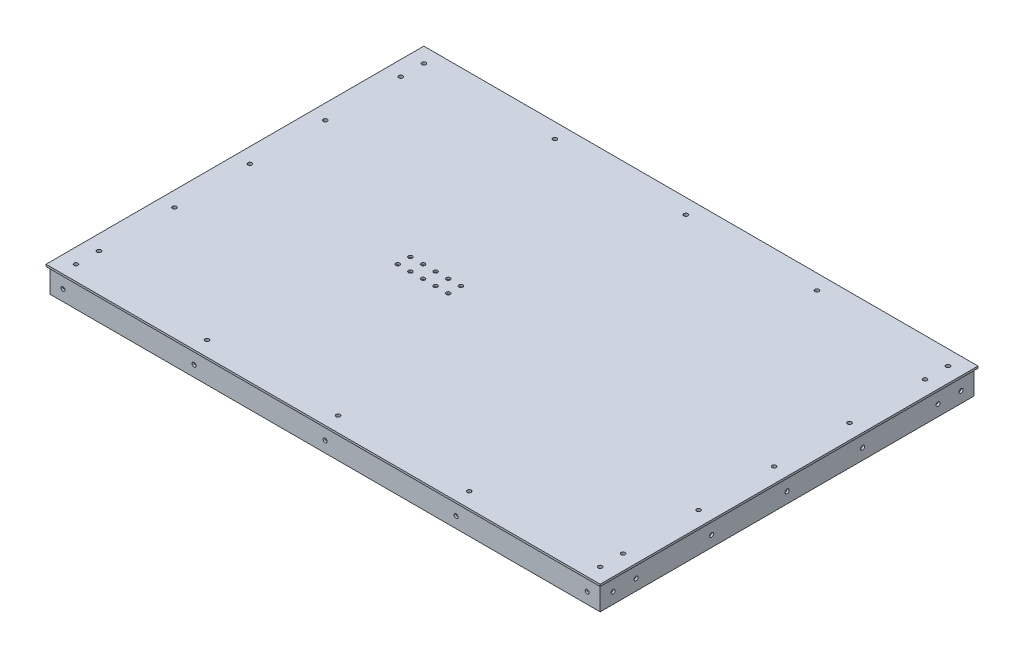
from build123d import *

# Parameters (mm, degrees)
ESQUISSE2_W              = 436.825
ESQUISSE2_H              = 296.825
ESQUISSE2_W_2            = 398.725
ESQUISSE2_H_2            = 258.725
BOSS_EXTRU_2_DEPTH       = 1.5875
ESQUISSE3_W              = 436.825
ESQUISSE3_H              = 296.825
ESQUISSE3_W_2            = 433.65
ESQUISSE3_H_2            = 293.65
BOSS_EXTRU_3_DEPTH       = 17.4625
ENL_V_MAT_EXTRU_1_REACH  = 21.05
ESQUISSE6_R              = 1.5875
ENL_V_MAT_EXTRU_2_REACH  = 3.588
ESQUISSE7_R              = 1.5875
ENL_V_MAT_EXTRU_3_REACH  = 3.588
ESQUISSE8_R              = 1.5875
ENL_V_MAT_EXTRU_4_REACH  = 3.588
ESQUISSE9_R              = 1.5875
ENL_V_MAT_EXTRU_6_REACH  = 298.825
ESQUISSE10_R             = 2
ESQUISSE1_W              = 440
ESQUISSE1_H              = 300
ESQUISSE1_R              = 1.5875
BOSS_EXTRU_7_DEPTH       = 1.5875
ENL_V_MAT_EXTRU_10_REACH = 5.175
ESQUISSE16_R             = 1.5875
ENL_V_MAT_EXTRU_11_REACH = 22.637
ESQUISSE17_R             = 1.5875


with BuildPart() as part:
    # Esquisse2 → Boss.-Extru.2 (new body)
    with BuildSketch(Plane(origin=(0, 0, 0), x_dir=(1, 0, 0), z_dir=(0, 1, 0))):
        with Locations((-37.473544974, -105.522486772)):
            Rectangle(ESQUISSE2_W, ESQUISSE2_H)
        with Locations((-37.473544974, -105.522486772)):
            Rectangle(ESQUISSE2_W_2, ESQUISSE2_H_2, mode=Mode.SUBTRACT)
    extrude(amount=BOSS_EXTRU_2_DEPTH)

    # Esquisse3 → Boss.-Extru.3 (add)
    with BuildSketch(Plane(origin=(0, 0, 0), x_dir=(1, 0, 0), z_dir=(0, 1, 0))):
        with Locations((-37.473544974, -105.522486772)):
            Rectangle(ESQUISSE3_W, ESQUISSE3_H)
        with Locations((-37.473544974, -105.522486772)):
            Rectangle(ESQUISSE3_W_2, ESQUISSE3_H_2, mode=Mode.SUBTRACT)
    extrude(amount=-BOSS_EXTRU_3_DEPTH)

    # Esquisse6 → Enlèv. mat.-Extru.1 (cut, up to next)
    with BuildSketch(Plane(origin=(0, 1.5875, 0), x_dir=(1, 0, 0), z_dir=(0, 1, 0)), mode=Mode.PRIVATE) as enl_v_mat_extru_1_sk1:
        with Locations((-245.567294974, -243.616236772)):
            Circle(ESQUISSE6_R)
    enl_v_mat_extru_1_tool1 = extrude(enl_v_mat_extru_1_sk1.sketch, amount=-ENL_V_MAT_EXTRU_1_REACH, mode=Mode.PRIVATE) & part.part
    add(enl_v_mat_extru_1_tool1.solids().sort_by_distance((-245.567295, 1.5875, 243.616237))[0], mode=Mode.SUBTRACT)
    # Esquisse6 → Enlèv. mat.-Extru.1 (cut, up to next)
    with BuildSketch(Plane(origin=(0, 1.5875, 0), x_dir=(1, 0, 0), z_dir=(0, 1, 0)), mode=Mode.PRIVATE) as enl_v_mat_extru_1_sk2:
        with Locations((170.620205026, -243.616236772)):
            Circle(ESQUISSE6_R)
    enl_v_mat_extru_1_tool2 = extrude(enl_v_mat_extru_1_sk2.sketch, amount=-ENL_V_MAT_EXTRU_1_REACH, mode=Mode.PRIVATE) & part.part
    add(enl_v_mat_extru_1_tool2.solids().sort_by_distance((170.620205, 1.5875, 243.616237))[0], mode=Mode.SUBTRACT)
    # Esquisse6 → Enlèv. mat.-Extru.1 (cut, up to next)
    with BuildSketch(Plane(origin=(0, 1.5875, 0), x_dir=(1, 0, 0), z_dir=(0, 1, 0)), mode=Mode.PRIVATE) as enl_v_mat_extru_1_sk3:
        with Locations((-245.567294974, 32.571263228)):
            Circle(ESQUISSE6_R)
    enl_v_mat_extru_1_tool3 = extrude(enl_v_mat_extru_1_sk3.sketch, amount=-ENL_V_MAT_EXTRU_1_REACH, mode=Mode.PRIVATE) & part.part
    add(enl_v_mat_extru_1_tool3.solids().sort_by_distance((-245.567295, 1.5875, -32.571263))[0], mode=Mode.SUBTRACT)
    # Esquisse6 → Enlèv. mat.-Extru.1 (cut, up to next)
    with BuildSketch(Plane(origin=(0, 1.5875, 0), x_dir=(1, 0, 0), z_dir=(0, 1, 0)), mode=Mode.PRIVATE) as enl_v_mat_extru_1_sk4:
        with Locations((170.620205026, 32.571263228)):
            Circle(ESQUISSE6_R)
    enl_v_mat_extru_1_tool4 = extrude(enl_v_mat_extru_1_sk4.sketch, amount=-ENL_V_MAT_EXTRU_1_REACH, mode=Mode.PRIVATE) & part.part
    add(enl_v_mat_extru_1_tool4.solids().sort_by_distance((170.620205, 1.5875, -32.571263))[0], mode=Mode.SUBTRACT)
    # Esquisse6 → Enlèv. mat.-Extru.1 (cut, up to next)
    with BuildSketch(Plane(origin=(0, 1.5875, 0), x_dir=(1, 0, 0), z_dir=(0, 1, 0)), mode=Mode.PRIVATE) as enl_v_mat_extru_1_sk5:
        with Locations((-141.520419974, -243.616236772)):
            Circle(ESQUISSE6_R)
    enl_v_mat_extru_1_tool5 = extrude(enl_v_mat_extru_1_sk5.sketch, amount=-ENL_V_MAT_EXTRU_1_REACH, mode=Mode.PRIVATE) & part.part
    add(enl_v_mat_extru_1_tool5.solids().sort_by_distance((-141.52042, 1.5875, 243.616237))[0], mode=Mode.SUBTRACT)
    # Esquisse6 → Enlèv. mat.-Extru.1 (cut, up to next)
    with BuildSketch(Plane(origin=(0, 1.5875, 0), x_dir=(1, 0, 0), z_dir=(0, 1, 0)), mode=Mode.PRIVATE) as enl_v_mat_extru_1_sk6:
        with Locations((66.573330026, -243.616236772)):
            Circle(ESQUISSE6_R)
    enl_v_mat_extru_1_tool6 = extrude(enl_v_mat_extru_1_sk6.sketch, amount=-ENL_V_MAT_EXTRU_1_REACH, mode=Mode.PRIVATE) & part.part
    add(enl_v_mat_extru_1_tool6.solids().sort_by_distance((66.57333, 1.5875, 243.616237))[0], mode=Mode.SUBTRACT)
    # Esquisse6 → Enlèv. mat.-Extru.1 (cut, up to next)
    with BuildSketch(Plane(origin=(0, 1.5875, 0), x_dir=(1, 0, 0), z_dir=(0, 1, 0)), mode=Mode.PRIVATE) as enl_v_mat_extru_1_sk7:
        with Locations((66.573330026, 32.571263228)):
            Circle(ESQUISSE6_R)
    enl_v_mat_extru_1_tool7 = extrude(enl_v_mat_extru_1_sk7.sketch, amount=-ENL_V_MAT_EXTRU_1_REACH, mode=Mode.PRIVATE) & part.part
    add(enl_v_mat_extru_1_tool7.solids().sort_by_distance((66.57333, 1.5875, -32.571263))[0], mode=Mode.SUBTRACT)
    # Esquisse6 → Enlèv. mat.-Extru.1 (cut, up to next)
    with BuildSketch(Plane(origin=(0, 1.5875, 0), x_dir=(1, 0, 0), z_dir=(0, 1, 0)), mode=Mode.PRIVATE) as enl_v_mat_extru_1_sk8:
        with Locations((-141.520419974, 32.571263228)):
            Circle(ESQUISSE6_R)
    enl_v_mat_extru_1_tool8 = extrude(enl_v_mat_extru_1_sk8.sketch, amount=-ENL_V_MAT_EXTRU_1_REACH, mode=Mode.PRIVATE) & part.part
    add(enl_v_mat_extru_1_tool8.solids().sort_by_distance((-141.52042, 1.5875, -32.571263))[0], mode=Mode.SUBTRACT)
    # Esquisse6 → Enlèv. mat.-Extru.1 (cut, up to next)
    with BuildSketch(Plane(origin=(0, 1.5875, 0), x_dir=(1, 0, 0), z_dir=(0, 1, 0)), mode=Mode.PRIVATE) as enl_v_mat_extru_1_sk9:
        with Locations((170.620205026, -45.603736772)):
            Circle(ESQUISSE6_R)
    enl_v_mat_extru_1_tool9 = extrude(enl_v_mat_extru_1_sk9.sketch, amount=-ENL_V_MAT_EXTRU_1_REACH, mode=Mode.PRIVATE) & part.part
    add(enl_v_mat_extru_1_tool9.solids().sort_by_distance((170.620205, 1.5875, 45.603737))[0], mode=Mode.SUBTRACT)
    # Esquisse6 → Enlèv. mat.-Extru.1 (cut, up to next)
    with BuildSketch(Plane(origin=(0, 1.5875, 0), x_dir=(1, 0, 0), z_dir=(0, 1, 0)), mode=Mode.PRIVATE) as enl_v_mat_extru_1_sk10:
        with Locations((-37.473544974, -243.616236772)):
            Circle(ESQUISSE6_R)
    enl_v_mat_extru_1_tool10 = extrude(enl_v_mat_extru_1_sk10.sketch, amount=-ENL_V_MAT_EXTRU_1_REACH, mode=Mode.PRIVATE) & part.part
    add(enl_v_mat_extru_1_tool10.solids().sort_by_distance((-37.473545, 1.5875, 243.616237))[0], mode=Mode.SUBTRACT)
    # Esquisse6 → Enlèv. mat.-Extru.1 (cut, up to next)
    with BuildSketch(Plane(origin=(0, 1.5875, 0), x_dir=(1, 0, 0), z_dir=(0, 1, 0)), mode=Mode.PRIVATE) as enl_v_mat_extru_1_sk11:
        with Locations((-37.473544974, 32.571263228)):
            Circle(ESQUISSE6_R)
    enl_v_mat_extru_1_tool11 = extrude(enl_v_mat_extru_1_sk11.sketch, amount=-ENL_V_MAT_EXTRU_1_REACH, mode=Mode.PRIVATE) & part.part
    add(enl_v_mat_extru_1_tool11.solids().sort_by_distance((-37.473545, 1.5875, -32.571263))[0], mode=Mode.SUBTRACT)
    # Esquisse6 → Enlèv. mat.-Extru.1 (cut, up to next)
    with BuildSketch(Plane(origin=(0, 1.5875, 0), x_dir=(1, 0, 0), z_dir=(0, 1, 0)), mode=Mode.PRIVATE) as enl_v_mat_extru_1_sk12:
        with Locations((170.620205026, -165.441236772)):
            Circle(ESQUISSE6_R)
    enl_v_mat_extru_1_tool12 = extrude(enl_v_mat_extru_1_sk12.sketch, amount=-ENL_V_MAT_EXTRU_1_REACH, mode=Mode.PRIVATE) & part.part
    add(enl_v_mat_extru_1_tool12.solids().sort_by_distance((170.620205, 1.5875, 165.441237))[0], mode=Mode.SUBTRACT)
    # Esquisse6 → Enlèv. mat.-Extru.1 (cut, up to next)
    with BuildSketch(Plane(origin=(0, 1.5875, 0), x_dir=(1, 0, 0), z_dir=(0, 1, 0)), mode=Mode.PRIVATE) as enl_v_mat_extru_1_sk13:
        with Locations((-245.567294974, -165.441236772)):
            Circle(ESQUISSE6_R)
    enl_v_mat_extru_1_tool13 = extrude(enl_v_mat_extru_1_sk13.sketch, amount=-ENL_V_MAT_EXTRU_1_REACH, mode=Mode.PRIVATE) & part.part
    add(enl_v_mat_extru_1_tool13.solids().sort_by_distance((-245.567295, 1.5875, 165.441237))[0], mode=Mode.SUBTRACT)
    # Esquisse6 → Enlèv. mat.-Extru.1 (cut, up to next)
    with BuildSketch(Plane(origin=(0, 1.5875, 0), x_dir=(1, 0, 0), z_dir=(0, 1, 0)), mode=Mode.PRIVATE) as enl_v_mat_extru_1_sk14:
        with Locations((-245.567294974, -45.603736772)):
            Circle(ESQUISSE6_R)
    enl_v_mat_extru_1_tool14 = extrude(enl_v_mat_extru_1_sk14.sketch, amount=-ENL_V_MAT_EXTRU_1_REACH, mode=Mode.PRIVATE) & part.part
    add(enl_v_mat_extru_1_tool14.solids().sort_by_distance((-245.567295, 1.5875, 45.603737))[0], mode=Mode.SUBTRACT)
    # Esquisse6 → Enlèv. mat.-Extru.1 (cut, up to next)
    with BuildSketch(Plane(origin=(0, 1.5875, 0), x_dir=(1, 0, 0), z_dir=(0, 1, 0)), mode=Mode.PRIVATE) as enl_v_mat_extru_1_sk15:
        with Locations((-245.567294974, -225.359986772)):
            Circle(ESQUISSE6_R)
    enl_v_mat_extru_1_tool15 = extrude(enl_v_mat_extru_1_sk15.sketch, amount=-ENL_V_MAT_EXTRU_1_REACH, mode=Mode.PRIVATE) & part.part
    add(enl_v_mat_extru_1_tool15.solids().sort_by_distance((-245.567295, 1.5875, 225.359987))[0], mode=Mode.SUBTRACT)
    # Esquisse6 → Enlèv. mat.-Extru.1 (cut, up to next)
    with BuildSketch(Plane(origin=(0, 1.5875, 0), x_dir=(1, 0, 0), z_dir=(0, 1, 0)), mode=Mode.PRIVATE) as enl_v_mat_extru_1_sk16:
        with Locations((-245.567294974, 14.315013228)):
            Circle(ESQUISSE6_R)
    enl_v_mat_extru_1_tool16 = extrude(enl_v_mat_extru_1_sk16.sketch, amount=-ENL_V_MAT_EXTRU_1_REACH, mode=Mode.PRIVATE) & part.part
    add(enl_v_mat_extru_1_tool16.solids().sort_by_distance((-245.567295, 1.5875, -14.315013))[0], mode=Mode.SUBTRACT)
    # Esquisse6 → Enlèv. mat.-Extru.1 (cut, up to next)
    with BuildSketch(Plane(origin=(0, 1.5875, 0), x_dir=(1, 0, 0), z_dir=(0, 1, 0)), mode=Mode.PRIVATE) as enl_v_mat_extru_1_sk17:
        with Locations((170.620205026, 14.315013228)):
            Circle(ESQUISSE6_R)
    enl_v_mat_extru_1_tool17 = extrude(enl_v_mat_extru_1_sk17.sketch, amount=-ENL_V_MAT_EXTRU_1_REACH, mode=Mode.PRIVATE) & part.part
    add(enl_v_mat_extru_1_tool17.solids().sort_by_distance((170.620205, 1.5875, -14.315013))[0], mode=Mode.SUBTRACT)
    # Esquisse6 → Enlèv. mat.-Extru.1 (cut, up to next)
    with BuildSketch(Plane(origin=(0, 1.5875, 0), x_dir=(1, 0, 0), z_dir=(0, 1, 0)), mode=Mode.PRIVATE) as enl_v_mat_extru_1_sk18:
        with Locations((170.620205026, -225.359986772)):
            Circle(ESQUISSE6_R)
    enl_v_mat_extru_1_tool18 = extrude(enl_v_mat_extru_1_sk18.sketch, amount=-ENL_V_MAT_EXTRU_1_REACH, mode=Mode.PRIVATE) & part.part
    add(enl_v_mat_extru_1_tool18.solids().sort_by_distance((170.620205, 1.5875, 225.359987))[0], mode=Mode.SUBTRACT)
    # Esquisse6 → Enlèv. mat.-Extru.1 (cut, up to next)
    with BuildSketch(Plane(origin=(0, 1.5875, 0), x_dir=(1, 0, 0), z_dir=(0, 1, 0)), mode=Mode.PRIVATE) as enl_v_mat_extru_1_sk19:
        with Locations((-245.567294974, -105.522486772)):
            Circle(ESQUISSE6_R)
    enl_v_mat_extru_1_tool19 = extrude(enl_v_mat_extru_1_sk19.sketch, amount=-ENL_V_MAT_EXTRU_1_REACH, mode=Mode.PRIVATE) & part.part
    add(enl_v_mat_extru_1_tool19.solids().sort_by_distance((-245.567295, 1.5875, 105.522487))[0], mode=Mode.SUBTRACT)
    # Esquisse6 → Enlèv. mat.-Extru.1 (cut, up to next)
    with BuildSketch(Plane(origin=(0, 1.5875, 0), x_dir=(1, 0, 0), z_dir=(0, 1, 0)), mode=Mode.PRIVATE) as enl_v_mat_extru_1_sk20:
        with Locations((170.620205026, -105.522486772)):
            Circle(ESQUISSE6_R)
    enl_v_mat_extru_1_tool20 = extrude(enl_v_mat_extru_1_sk20.sketch, amount=-ENL_V_MAT_EXTRU_1_REACH, mode=Mode.PRIVATE) & part.part
    add(enl_v_mat_extru_1_tool20.solids().sort_by_distance((170.620205, 1.5875, 105.522487))[0], mode=Mode.SUBTRACT)

    # Esquisse7 → Enlèv. mat.-Extru.2 (cut, up to next)
    with BuildSketch(Plane.ZY.offset(-179.351455026), mode=Mode.PRIVATE) as enl_v_mat_extru_2_sk1:
        with Locations((-32.571263228, -8.73125)):
            Circle(ESQUISSE7_R)
    enl_v_mat_extru_2_tool1 = extrude(enl_v_mat_extru_2_sk1.sketch, amount=-ENL_V_MAT_EXTRU_2_REACH, mode=Mode.PRIVATE) & part.part
    add(enl_v_mat_extru_2_tool1.solids().sort_by_distance((179.351455, -8.73125, -32.571263))[0], mode=Mode.SUBTRACT)
    # Esquisse7 → Enlèv. mat.-Extru.2 (cut, up to next)
    with BuildSketch(Plane.ZY.offset(-179.351455026), mode=Mode.PRIVATE) as enl_v_mat_extru_2_sk2:
        with Locations((-14.315013228, -8.73125)):
            Circle(ESQUISSE7_R)
    enl_v_mat_extru_2_tool2 = extrude(enl_v_mat_extru_2_sk2.sketch, amount=-ENL_V_MAT_EXTRU_2_REACH, mode=Mode.PRIVATE) & part.part
    add(enl_v_mat_extru_2_tool2.solids().sort_by_distance((179.351455, -8.73125, -14.315013))[0], mode=Mode.SUBTRACT)
    # Esquisse7 → Enlèv. mat.-Extru.2 (cut, up to next)
    with BuildSketch(Plane.ZY.offset(-179.351455026), mode=Mode.PRIVATE) as enl_v_mat_extru_2_sk3:
        with Locations((45.603736772, -8.73125)):
            Circle(ESQUISSE7_R)
    enl_v_mat_extru_2_tool3 = extrude(enl_v_mat_extru_2_sk3.sketch, amount=-ENL_V_MAT_EXTRU_2_REACH, mode=Mode.PRIVATE) & part.part
    add(enl_v_mat_extru_2_tool3.solids().sort_by_distance((179.351455, -8.73125, 45.603737))[0], mode=Mode.SUBTRACT)
    # Esquisse7 → Enlèv. mat.-Extru.2 (cut, up to next)
    with BuildSketch(Plane.ZY.offset(-179.351455026), mode=Mode.PRIVATE) as enl_v_mat_extru_2_sk4:
        with Locations((105.522486772, -8.73125)):
            Circle(ESQUISSE7_R)
    enl_v_mat_extru_2_tool4 = extrude(enl_v_mat_extru_2_sk4.sketch, amount=-ENL_V_MAT_EXTRU_2_REACH, mode=Mode.PRIVATE) & part.part
    add(enl_v_mat_extru_2_tool4.solids().sort_by_distance((179.351455, -8.73125, 105.522487))[0], mode=Mode.SUBTRACT)
    # Esquisse7 → Enlèv. mat.-Extru.2 (cut, up to next)
    with BuildSketch(Plane.ZY.offset(-179.351455026), mode=Mode.PRIVATE) as enl_v_mat_extru_2_sk5:
        with Locations((165.441236772, -8.73125)):
            Circle(ESQUISSE7_R)
    enl_v_mat_extru_2_tool5 = extrude(enl_v_mat_extru_2_sk5.sketch, amount=-ENL_V_MAT_EXTRU_2_REACH, mode=Mode.PRIVATE) & part.part
    add(enl_v_mat_extru_2_tool5.solids().sort_by_distance((179.351455, -8.73125, 165.441237))[0], mode=Mode.SUBTRACT)
    # Esquisse7 → Enlèv. mat.-Extru.2 (cut, up to next)
    with BuildSketch(Plane.ZY.offset(-179.351455026), mode=Mode.PRIVATE) as enl_v_mat_extru_2_sk6:
        with Locations((225.359986772, -8.73125)):
            Circle(ESQUISSE7_R)
    enl_v_mat_extru_2_tool6 = extrude(enl_v_mat_extru_2_sk6.sketch, amount=-ENL_V_MAT_EXTRU_2_REACH, mode=Mode.PRIVATE) & part.part
    add(enl_v_mat_extru_2_tool6.solids().sort_by_distance((179.351455, -8.73125, 225.359987))[0], mode=Mode.SUBTRACT)
    # Esquisse7 → Enlèv. mat.-Extru.2 (cut, up to next)
    with BuildSketch(Plane.ZY.offset(-179.351455026), mode=Mode.PRIVATE) as enl_v_mat_extru_2_sk7:
        with Locations((243.616236772, -8.73125)):
            Circle(ESQUISSE7_R)
    enl_v_mat_extru_2_tool7 = extrude(enl_v_mat_extru_2_sk7.sketch, amount=-ENL_V_MAT_EXTRU_2_REACH, mode=Mode.PRIVATE) & part.part
    add(enl_v_mat_extru_2_tool7.solids().sort_by_distance((179.351455, -8.73125, 243.616237))[0], mode=Mode.SUBTRACT)

    # Esquisse8 → Enlèv. mat.-Extru.3 (cut, up to next)
    with BuildSketch(Plane(origin=(-254.298544974, 0, 0), x_dir=(0, 0, -1), z_dir=(1, 0, 0)), mode=Mode.PRIVATE) as enl_v_mat_extru_3_sk1:
        with Locations((-243.616236772, -8.73125)):
            Circle(ESQUISSE8_R)
    enl_v_mat_extru_3_tool1 = extrude(enl_v_mat_extru_3_sk1.sketch, amount=-ENL_V_MAT_EXTRU_3_REACH, mode=Mode.PRIVATE) & part.part
    add(enl_v_mat_extru_3_tool1.solids().sort_by_distance((-254.298545, -8.73125, 243.616237))[0], mode=Mode.SUBTRACT)
    # Esquisse8 → Enlèv. mat.-Extru.3 (cut, up to next)
    with BuildSketch(Plane(origin=(-254.298544974, 0, 0), x_dir=(0, 0, -1), z_dir=(1, 0, 0)), mode=Mode.PRIVATE) as enl_v_mat_extru_3_sk2:
        with Locations((-225.359986772, -8.73125)):
            Circle(ESQUISSE8_R)
    enl_v_mat_extru_3_tool2 = extrude(enl_v_mat_extru_3_sk2.sketch, amount=-ENL_V_MAT_EXTRU_3_REACH, mode=Mode.PRIVATE) & part.part
    add(enl_v_mat_extru_3_tool2.solids().sort_by_distance((-254.298545, -8.73125, 225.359987))[0], mode=Mode.SUBTRACT)
    # Esquisse8 → Enlèv. mat.-Extru.3 (cut, up to next)
    with BuildSketch(Plane(origin=(-254.298544974, 0, 0), x_dir=(0, 0, -1), z_dir=(1, 0, 0)), mode=Mode.PRIVATE) as enl_v_mat_extru_3_sk3:
        with Locations((-165.441236772, -8.73125)):
            Circle(ESQUISSE8_R)
    enl_v_mat_extru_3_tool3 = extrude(enl_v_mat_extru_3_sk3.sketch, amount=-ENL_V_MAT_EXTRU_3_REACH, mode=Mode.PRIVATE) & part.part
    add(enl_v_mat_extru_3_tool3.solids().sort_by_distance((-254.298545, -8.73125, 165.441237))[0], mode=Mode.SUBTRACT)
    # Esquisse8 → Enlèv. mat.-Extru.3 (cut, up to next)
    with BuildSketch(Plane(origin=(-254.298544974, 0, 0), x_dir=(0, 0, -1), z_dir=(1, 0, 0)), mode=Mode.PRIVATE) as enl_v_mat_extru_3_sk4:
        with Locations((-105.522486772, -8.73125)):
            Circle(ESQUISSE8_R)
    enl_v_mat_extru_3_tool4 = extrude(enl_v_mat_extru_3_sk4.sketch, amount=-ENL_V_MAT_EXTRU_3_REACH, mode=Mode.PRIVATE) & part.part
    add(enl_v_mat_extru_3_tool4.solids().sort_by_distance((-254.298545, -8.73125, 105.522487))[0], mode=Mode.SUBTRACT)
    # Esquisse8 → Enlèv. mat.-Extru.3 (cut, up to next)
    with BuildSketch(Plane(origin=(-254.298544974, 0, 0), x_dir=(0, 0, -1), z_dir=(1, 0, 0)), mode=Mode.PRIVATE) as enl_v_mat_extru_3_sk5:
        with Locations((-45.603736772, -8.73125)):
            Circle(ESQUISSE8_R)
    enl_v_mat_extru_3_tool5 = extrude(enl_v_mat_extru_3_sk5.sketch, amount=-ENL_V_MAT_EXTRU_3_REACH, mode=Mode.PRIVATE) & part.part
    add(enl_v_mat_extru_3_tool5.solids().sort_by_distance((-254.298545, -8.73125, 45.603737))[0], mode=Mode.SUBTRACT)
    # Esquisse8 → Enlèv. mat.-Extru.3 (cut, up to next)
    with BuildSketch(Plane(origin=(-254.298544974, 0, 0), x_dir=(0, 0, -1), z_dir=(1, 0, 0)), mode=Mode.PRIVATE) as enl_v_mat_extru_3_sk6:
        with Locations((14.315013228, -8.73125)):
            Circle(ESQUISSE8_R)
    enl_v_mat_extru_3_tool6 = extrude(enl_v_mat_extru_3_sk6.sketch, amount=-ENL_V_MAT_EXTRU_3_REACH, mode=Mode.PRIVATE) & part.part
    add(enl_v_mat_extru_3_tool6.solids().sort_by_distance((-254.298545, -8.73125, -14.315013))[0], mode=Mode.SUBTRACT)
    # Esquisse8 → Enlèv. mat.-Extru.3 (cut, up to next)
    with BuildSketch(Plane(origin=(-254.298544974, 0, 0), x_dir=(0, 0, -1), z_dir=(1, 0, 0)), mode=Mode.PRIVATE) as enl_v_mat_extru_3_sk7:
        with Locations((32.571263228, -8.73125)):
            Circle(ESQUISSE8_R)
    enl_v_mat_extru_3_tool7 = extrude(enl_v_mat_extru_3_sk7.sketch, amount=-ENL_V_MAT_EXTRU_3_REACH, mode=Mode.PRIVATE) & part.part
    add(enl_v_mat_extru_3_tool7.solids().sort_by_distance((-254.298545, -8.73125, -32.571263))[0], mode=Mode.SUBTRACT)

    # Esquisse9 → Enlèv. mat.-Extru.4 (cut, up to next)
    with BuildSketch(Plane.XY.offset(-41.302513228), mode=Mode.PRIVATE) as enl_v_mat_extru_4_sk1:
        with Locations((-245.567294974, -8.73125)):
            Circle(ESQUISSE9_R)
    enl_v_mat_extru_4_tool1 = extrude(enl_v_mat_extru_4_sk1.sketch, amount=-ENL_V_MAT_EXTRU_4_REACH, mode=Mode.PRIVATE) & part.part
    add(enl_v_mat_extru_4_tool1.solids().sort_by_distance((-245.567295, -8.73125, -41.302513))[0], mode=Mode.SUBTRACT)
    # Esquisse9 → Enlèv. mat.-Extru.4 (cut, up to next)
    with BuildSketch(Plane.XY.offset(-41.302513228), mode=Mode.PRIVATE) as enl_v_mat_extru_4_sk2:
        with Locations((-141.520419974, -8.73125)):
            Circle(ESQUISSE9_R)
    enl_v_mat_extru_4_tool2 = extrude(enl_v_mat_extru_4_sk2.sketch, amount=-ENL_V_MAT_EXTRU_4_REACH, mode=Mode.PRIVATE) & part.part
    add(enl_v_mat_extru_4_tool2.solids().sort_by_distance((-141.52042, -8.73125, -41.302513))[0], mode=Mode.SUBTRACT)
    # Esquisse9 → Enlèv. mat.-Extru.4 (cut, up to next)
    with BuildSketch(Plane.XY.offset(-41.302513228), mode=Mode.PRIVATE) as enl_v_mat_extru_4_sk3:
        with Locations((-37.473544974, -8.73125)):
            Circle(ESQUISSE9_R)
    enl_v_mat_extru_4_tool3 = extrude(enl_v_mat_extru_4_sk3.sketch, amount=-ENL_V_MAT_EXTRU_4_REACH, mode=Mode.PRIVATE) & part.part
    add(enl_v_mat_extru_4_tool3.solids().sort_by_distance((-37.473545, -8.73125, -41.302513))[0], mode=Mode.SUBTRACT)
    # Esquisse9 → Enlèv. mat.-Extru.4 (cut, up to next)
    with BuildSketch(Plane.XY.offset(-41.302513228), mode=Mode.PRIVATE) as enl_v_mat_extru_4_sk4:
        with Locations((66.573330026, -8.73125)):
            Circle(ESQUISSE9_R)
    enl_v_mat_extru_4_tool4 = extrude(enl_v_mat_extru_4_sk4.sketch, amount=-ENL_V_MAT_EXTRU_4_REACH, mode=Mode.PRIVATE) & part.part
    add(enl_v_mat_extru_4_tool4.solids().sort_by_distance((66.57333, -8.73125, -41.302513))[0], mode=Mode.SUBTRACT)
    # Esquisse9 → Enlèv. mat.-Extru.4 (cut, up to next)
    with BuildSketch(Plane.XY.offset(-41.302513228), mode=Mode.PRIVATE) as enl_v_mat_extru_4_sk5:
        with Locations((170.620205026, -8.73125)):
            Circle(ESQUISSE9_R)
    enl_v_mat_extru_4_tool5 = extrude(enl_v_mat_extru_4_sk5.sketch, amount=-ENL_V_MAT_EXTRU_4_REACH, mode=Mode.PRIVATE) & part.part
    add(enl_v_mat_extru_4_tool5.solids().sort_by_distance((170.620205, -8.73125, -41.302513))[0], mode=Mode.SUBTRACT)

    # Esquisse10 → Enlèv. mat.-Extru.6 (cut, up to next)
    with BuildSketch(Plane(origin=(0, 0, -42.890013228), x_dir=(-1, 0, 0), z_dir=(0, 0, -1)), mode=Mode.PRIVATE) as enl_v_mat_extru_6_sk1:
        with Locations((53.746982474, -4.8)):
            Circle(ESQUISSE10_R)
    enl_v_mat_extru_6_tool1 = extrude(enl_v_mat_extru_6_sk1.sketch, amount=-ENL_V_MAT_EXTRU_6_REACH, mode=Mode.PRIVATE) & part.part
    add(enl_v_mat_extru_6_tool1.solids().sort_by_distance((-53.746982, -4.8, -42.890013))[0], mode=Mode.SUBTRACT)
    # Esquisse10 → Enlèv. mat.-Extru.6 (cut, up to next)
    with BuildSketch(Plane(origin=(0, 0, -42.890013228), x_dir=(-1, 0, 0), z_dir=(0, 0, -1)), mode=Mode.PRIVATE) as enl_v_mat_extru_6_sk2:
        with Locations((125.246982474, -4.8)):
            Circle(ESQUISSE10_R)
    enl_v_mat_extru_6_tool2 = extrude(enl_v_mat_extru_6_sk2.sketch, amount=-ENL_V_MAT_EXTRU_6_REACH, mode=Mode.PRIVATE) & part.part
    add(enl_v_mat_extru_6_tool2.solids().sort_by_distance((-125.246982, -4.8, -42.890013))[0], mode=Mode.SUBTRACT)

    # Esquisse1 → Boss.-Extru.7 (add)
    with BuildSketch(Plane(origin=(0, 1.5875, 0), x_dir=(1, 0, 0), z_dir=(0, 1, 0))):
        with Locations((-37.473544974, -105.522486772)):
            Rectangle(ESQUISSE1_W, ESQUISSE1_H)
        with Locations((66.573330026, -243.616236772)):
            Circle(ESQUISSE1_R, mode=Mode.SUBTRACT)
        with Locations((-37.473544974, -243.616236772)):
            Circle(ESQUISSE1_R, mode=Mode.SUBTRACT)
        with Locations((-141.520419974, -243.616236772)):
            Circle(ESQUISSE1_R, mode=Mode.SUBTRACT)
        with Locations((-245.567294974, -243.616236772)):
            Circle(ESQUISSE1_R, mode=Mode.SUBTRACT)
        with Locations((-245.567294974, -225.359986772)):
            Circle(ESQUISSE1_R, mode=Mode.SUBTRACT)
        with Locations((-245.567294974, -165.441236772)):
            Circle(ESQUISSE1_R, mode=Mode.SUBTRACT)
        with Locations((-245.567294974, -105.522486772)):
            Circle(ESQUISSE1_R, mode=Mode.SUBTRACT)
        with Locations((-245.567294974, -45.603736772)):
            Circle(ESQUISSE1_R, mode=Mode.SUBTRACT)
        with Locations((-245.567294974, 14.315013228)):
            Circle(ESQUISSE1_R, mode=Mode.SUBTRACT)
        with Locations((-245.567294974, 32.571263228)):
            Circle(ESQUISSE1_R, mode=Mode.SUBTRACT)
        with Locations((-141.520419974, 32.571263228)):
            Circle(ESQUISSE1_R, mode=Mode.SUBTRACT)
        with Locations((-37.473544974, 32.571263228)):
            Circle(ESQUISSE1_R, mode=Mode.SUBTRACT)
        with Locations((66.573330026, 32.571263228)):
            Circle(ESQUISSE1_R, mode=Mode.SUBTRACT)
        with Locations((170.620205026, 32.571263228)):
            Circle(ESQUISSE1_R, mode=Mode.SUBTRACT)
        with Locations((170.620205026, 14.315013228)):
            Circle(ESQUISSE1_R, mode=Mode.SUBTRACT)
        with Locations((170.620205026, -243.616236772)):
            Circle(ESQUISSE1_R, mode=Mode.SUBTRACT)
        with Locations((170.620205026, -225.359986772)):
            Circle(ESQUISSE1_R, mode=Mode.SUBTRACT)
        with Locations((170.620205026, -165.441236772)):
            Circle(ESQUISSE1_R, mode=Mode.SUBTRACT)
        with Locations((170.620205026, -105.522486772)):
            Circle(ESQUISSE1_R, mode=Mode.SUBTRACT)
        with Locations((170.620205026, -45.603736772)):
            Circle(ESQUISSE1_R, mode=Mode.SUBTRACT)
    extrude(amount=BOSS_EXTRU_7_DEPTH)

    # Esquisse16 → Enlèv. mat.-Extru.10 (cut, up to next)
    with BuildSketch(Plane(origin=(0, 0, 252.347486772), x_dir=(-1, 0, 0), z_dir=(0, 0, -1)), mode=Mode.PRIVATE) as enl_v_mat_extru_10_sk1:
        with Locations((245.567294974, -8.73125)):
            Circle(ESQUISSE16_R)
    enl_v_mat_extru_10_tool1 = extrude(enl_v_mat_extru_10_sk1.sketch, amount=-ENL_V_MAT_EXTRU_10_REACH, mode=Mode.PRIVATE) & part.part
    add(enl_v_mat_extru_10_tool1.solids().sort_by_distance((-245.567295, -8.73125, 252.347487))[0], mode=Mode.SUBTRACT)
    # Esquisse16 → Enlèv. mat.-Extru.10 (cut, up to next)
    with BuildSketch(Plane(origin=(0, 0, 252.347486772), x_dir=(-1, 0, 0), z_dir=(0, 0, -1)), mode=Mode.PRIVATE) as enl_v_mat_extru_10_sk2:
        with Locations((141.520419974, -8.73125)):
            Circle(ESQUISSE16_R)
    enl_v_mat_extru_10_tool2 = extrude(enl_v_mat_extru_10_sk2.sketch, amount=-ENL_V_MAT_EXTRU_10_REACH, mode=Mode.PRIVATE) & part.part
    add(enl_v_mat_extru_10_tool2.solids().sort_by_distance((-141.52042, -8.73125, 252.347487))[0], mode=Mode.SUBTRACT)
    # Esquisse16 → Enlèv. mat.-Extru.10 (cut, up to next)
    with BuildSketch(Plane(origin=(0, 0, 252.347486772), x_dir=(-1, 0, 0), z_dir=(0, 0, -1)), mode=Mode.PRIVATE) as enl_v_mat_extru_10_sk3:
        with Locations((37.473544974, -8.73125)):
            Circle(ESQUISSE16_R)
    enl_v_mat_extru_10_tool3 = extrude(enl_v_mat_extru_10_sk3.sketch, amount=-ENL_V_MAT_EXTRU_10_REACH, mode=Mode.PRIVATE) & part.part
    add(enl_v_mat_extru_10_tool3.solids().sort_by_distance((-37.473545, -8.73125, 252.347487))[0], mode=Mode.SUBTRACT)
    # Esquisse16 → Enlèv. mat.-Extru.10 (cut, up to next)
    with BuildSketch(Plane(origin=(0, 0, 252.347486772), x_dir=(-1, 0, 0), z_dir=(0, 0, -1)), mode=Mode.PRIVATE) as enl_v_mat_extru_10_sk4:
        with Locations((-66.573330026, -8.73125)):
            Circle(ESQUISSE16_R)
    enl_v_mat_extru_10_tool4 = extrude(enl_v_mat_extru_10_sk4.sketch, amount=-ENL_V_MAT_EXTRU_10_REACH, mode=Mode.PRIVATE) & part.part
    add(enl_v_mat_extru_10_tool4.solids().sort_by_distance((66.57333, -8.73125, 252.347487))[0], mode=Mode.SUBTRACT)
    # Esquisse16 → Enlèv. mat.-Extru.10 (cut, up to next)
    with BuildSketch(Plane(origin=(0, 0, 252.347486772), x_dir=(-1, 0, 0), z_dir=(0, 0, -1)), mode=Mode.PRIVATE) as enl_v_mat_extru_10_sk5:
        with Locations((-170.620205026, -8.73125)):
            Circle(ESQUISSE16_R)
    enl_v_mat_extru_10_tool5 = extrude(enl_v_mat_extru_10_sk5.sketch, amount=-ENL_V_MAT_EXTRU_10_REACH, mode=Mode.PRIVATE) & part.part
    add(enl_v_mat_extru_10_tool5.solids().sort_by_distance((170.620205, -8.73125, 252.347487))[0], mode=Mode.SUBTRACT)

    # Esquisse17 → Enlèv. mat.-Extru.11 (cut, up to next)
    with BuildSketch(Plane(origin=(0, 3.175, 0), x_dir=(1, 0, 0), z_dir=(0, 1, 0)), mode=Mode.PRIVATE) as enl_v_mat_extru_11_sk1:
        with Locations((-77.792294974, -115.841236772)):
            Circle(ESQUISSE17_R)
    enl_v_mat_extru_11_tool1 = extrude(enl_v_mat_extru_11_sk1.sketch, amount=-ENL_V_MAT_EXTRU_11_REACH, mode=Mode.PRIVATE) & part.part
    add(enl_v_mat_extru_11_tool1.solids().sort_by_distance((-77.792295, 3.175, 115.841237))[0], mode=Mode.SUBTRACT)
    # Esquisse17 → Enlèv. mat.-Extru.11 (cut, up to next)
    with BuildSketch(Plane(origin=(0, 3.175, 0), x_dir=(1, 0, 0), z_dir=(0, 1, 0)), mode=Mode.PRIVATE) as enl_v_mat_extru_11_sk2:
        with Locations((-87.792294974, -115.841236772)):
            Circle(ESQUISSE17_R)
    enl_v_mat_extru_11_tool2 = extrude(enl_v_mat_extru_11_sk2.sketch, amount=-ENL_V_MAT_EXTRU_11_REACH, mode=Mode.PRIVATE) & part.part
    add(enl_v_mat_extru_11_tool2.solids().sort_by_distance((-87.792295, 3.175, 115.841237))[0], mode=Mode.SUBTRACT)
    # Esquisse17 → Enlèv. mat.-Extru.11 (cut, up to next)
    with BuildSketch(Plane(origin=(0, 3.175, 0), x_dir=(1, 0, 0), z_dir=(0, 1, 0)), mode=Mode.PRIVATE) as enl_v_mat_extru_11_sk3:
        with Locations((-97.792294974, -115.841236772)):
            Circle(ESQUISSE17_R)
    enl_v_mat_extru_11_tool3 = extrude(enl_v_mat_extru_11_sk3.sketch, amount=-ENL_V_MAT_EXTRU_11_REACH, mode=Mode.PRIVATE) & part.part
    add(enl_v_mat_extru_11_tool3.solids().sort_by_distance((-97.792295, 3.175, 115.841237))[0], mode=Mode.SUBTRACT)
    # Esquisse17 → Enlèv. mat.-Extru.11 (cut, up to next)
    with BuildSketch(Plane(origin=(0, 3.175, 0), x_dir=(1, 0, 0), z_dir=(0, 1, 0)), mode=Mode.PRIVATE) as enl_v_mat_extru_11_sk4:
        with Locations((-107.792294974, -115.841236772)):
            Circle(ESQUISSE17_R)
    enl_v_mat_extru_11_tool4 = extrude(enl_v_mat_extru_11_sk4.sketch, amount=-ENL_V_MAT_EXTRU_11_REACH, mode=Mode.PRIVATE) & part.part
    add(enl_v_mat_extru_11_tool4.solids().sort_by_distance((-107.792295, 3.175, 115.841237))[0], mode=Mode.SUBTRACT)
    # Esquisse17 → Enlèv. mat.-Extru.11 (cut, up to next)
    with BuildSketch(Plane(origin=(0, 3.175, 0), x_dir=(1, 0, 0), z_dir=(0, 1, 0)), mode=Mode.PRIVATE) as enl_v_mat_extru_11_sk5:
        with Locations((-117.792294974, -115.841236772)):
            Circle(ESQUISSE17_R)
    enl_v_mat_extru_11_tool5 = extrude(enl_v_mat_extru_11_sk5.sketch, amount=-ENL_V_MAT_EXTRU_11_REACH, mode=Mode.PRIVATE) & part.part
    add(enl_v_mat_extru_11_tool5.solids().sort_by_distance((-117.792295, 3.175, 115.841237))[0], mode=Mode.SUBTRACT)
    # Esquisse17 → Enlèv. mat.-Extru.11 (cut, up to next)
    with BuildSketch(Plane(origin=(0, 3.175, 0), x_dir=(1, 0, 0), z_dir=(0, 1, 0)), mode=Mode.PRIVATE) as enl_v_mat_extru_11_sk6:
        with Locations((-87.792294974, -105.841236772)):
            Circle(ESQUISSE17_R)
    enl_v_mat_extru_11_tool6 = extrude(enl_v_mat_extru_11_sk6.sketch, amount=-ENL_V_MAT_EXTRU_11_REACH, mode=Mode.PRIVATE) & part.part
    add(enl_v_mat_extru_11_tool6.solids().sort_by_distance((-87.792295, 3.175, 105.841237))[0], mode=Mode.SUBTRACT)
    # Esquisse17 → Enlèv. mat.-Extru.11 (cut, up to next)
    with BuildSketch(Plane(origin=(0, 3.175, 0), x_dir=(1, 0, 0), z_dir=(0, 1, 0)), mode=Mode.PRIVATE) as enl_v_mat_extru_11_sk7:
        with Locations((-97.792294974, -105.841236772)):
            Circle(ESQUISSE17_R)
    enl_v_mat_extru_11_tool7 = extrude(enl_v_mat_extru_11_sk7.sketch, amount=-ENL_V_MAT_EXTRU_11_REACH, mode=Mode.PRIVATE) & part.part
    add(enl_v_mat_extru_11_tool7.solids().sort_by_distance((-97.792295, 3.175, 105.841237))[0], mode=Mode.SUBTRACT)
    # Esquisse17 → Enlèv. mat.-Extru.11 (cut, up to next)
    with BuildSketch(Plane(origin=(0, 3.175, 0), x_dir=(1, 0, 0), z_dir=(0, 1, 0)), mode=Mode.PRIVATE) as enl_v_mat_extru_11_sk8:
        with Locations((-107.792294974, -105.841236772)):
            Circle(ESQUISSE17_R)
    enl_v_mat_extru_11_tool8 = extrude(enl_v_mat_extru_11_sk8.sketch, amount=-ENL_V_MAT_EXTRU_11_REACH, mode=Mode.PRIVATE) & part.part
    add(enl_v_mat_extru_11_tool8.solids().sort_by_distance((-107.792295, 3.175, 105.841237))[0], mode=Mode.SUBTRACT)
    # Esquisse17 → Enlèv. mat.-Extru.11 (cut, up to next)
    with BuildSketch(Plane(origin=(0, 3.175, 0), x_dir=(1, 0, 0), z_dir=(0, 1, 0)), mode=Mode.PRIVATE) as enl_v_mat_extru_11_sk9:
        with Locations((-117.792294974, -105.841236772)):
            Circle(ESQUISSE17_R)
    enl_v_mat_extru_11_tool9 = extrude(enl_v_mat_extru_11_sk9.sketch, amount=-ENL_V_MAT_EXTRU_11_REACH, mode=Mode.PRIVATE) & part.part
    add(enl_v_mat_extru_11_tool9.solids().sort_by_distance((-117.792295, 3.175, 105.841237))[0], mode=Mode.SUBTRACT)
    # Esquisse17 → Enlèv. mat.-Extru.11 (cut, up to next)
    with BuildSketch(Plane(origin=(0, 3.175, 0), x_dir=(1, 0, 0), z_dir=(0, 1, 0)), mode=Mode.PRIVATE) as enl_v_mat_extru_11_sk10:
        with Locations((-77.792294974, -105.841236772)):
            Circle(ESQUISSE17_R)
    enl_v_mat_extru_11_tool10 = extrude(enl_v_mat_extru_11_sk10.sketch, amount=-ENL_V_MAT_EXTRU_11_REACH, mode=Mode.PRIVATE) & part.part
    add(enl_v_mat_extru_11_tool10.solids().sort_by_distance((-77.792295, 3.175, 105.841237))[0], mode=Mode.SUBTRACT)


solid = part.part
